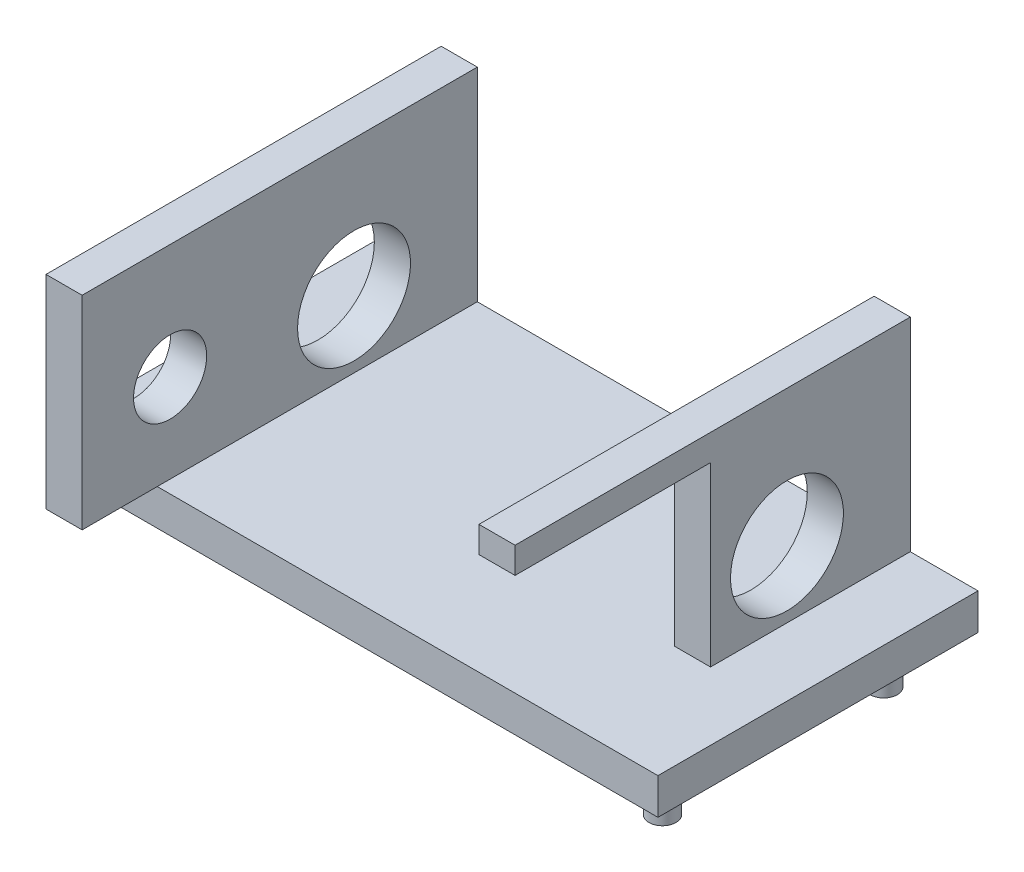
from build123d import *

# Parameters (mm, degrees)
SKETCH1_W               = 34
SKETCH1_H               = 18
BOSS_EXTRUDE1_DEPTH     = 2.032
SKETCH2_R               = 0.762
BOSS_EXTRUDE2_DEPTH     = 1.524
SKETCH4_W               = 2.032
SKETCH4_H               = 22.225
BOSS_EXTRUDE3_DEPTH     = 11.43
SKETCH3_R               = 3.175
SKETCH3_R_2             = 2.0574
CUT_EXTRUDE1_DEPTH      = 1
CUT_EXTRUDE1_DEPTH_BACK = 35
SKETCH5_W               = 12.0904
SKETCH5_H               = 9.9568
CUT_EXTRUDE2_DEPTH      = 2.032


with BuildPart() as part:
    # Sketch1 → Boss-Extrude1 (new body)
    with BuildSketch(Plane(origin=(0, 0, 0), x_dir=(1, 0, 0), z_dir=(0, 1, 0))):
        Rectangle(SKETCH1_W, SKETCH1_H)
    extrude(amount=BOSS_EXTRUDE1_DEPTH)

    # Sketch2 → Boss-Extrude2 (add)
    with BuildSketch(Plane(origin=(0, 0, 0), x_dir=(-1, 0, 0), z_dir=(0, -1, 0))):
        with Locations((-15.476, 5.224)):
            Circle(SKETCH2_R)
        with Locations((-15.476, -7.222)):
            Circle(SKETCH2_R)
        with Locations((15.476, -7.222)):
            Circle(SKETCH2_R)
        with Locations((15.476, 6.494)):
            Circle(SKETCH2_R)
    extrude(amount=BOSS_EXTRUDE2_DEPTH)

    # Sketch4 → Boss-Extrude3 (add)
    with BuildSketch(Plane(origin=(0, 2.032, 0), x_dir=(1, 0, 0), z_dir=(0, 1, 0))):
        with Locations((-12.174, -2.1125)):
            Rectangle(SKETCH4_W, SKETCH4_H)
        with Locations((12.174, -2.1125)):
            Rectangle(SKETCH4_W, SKETCH4_H)
    extrude(amount=BOSS_EXTRUDE3_DEPTH)

    # Sketch3 → Cut-Extrude1 (cut, two sides)
    with BuildSketch(Plane.ZY.offset(17)) as cut_extrude1_sk:
        with Locations((-2.0658, 5.7912)):
            Circle(SKETCH3_R)
        with Locations((8.276585961, 7.0104)):
            Circle(SKETCH3_R_2)
    extrude(amount=CUT_EXTRUDE1_DEPTH, mode=Mode.SUBTRACT)
    extrude(cut_extrude1_sk.sketch, amount=-CUT_EXTRUDE1_DEPTH_BACK, mode=Mode.SUBTRACT)

    # Sketch5 → Cut-Extrude2 (cut)
    with BuildSketch(Plane(origin=(13.19, 0, 0), x_dir=(0, 0, -1), z_dir=(1, 0, 0))):
        with Locations((-8.276585961, 7.0104)):
            Rectangle(SKETCH5_W, SKETCH5_H)
    extrude(amount=-CUT_EXTRUDE2_DEPTH, mode=Mode.SUBTRACT)


solid = part.part
